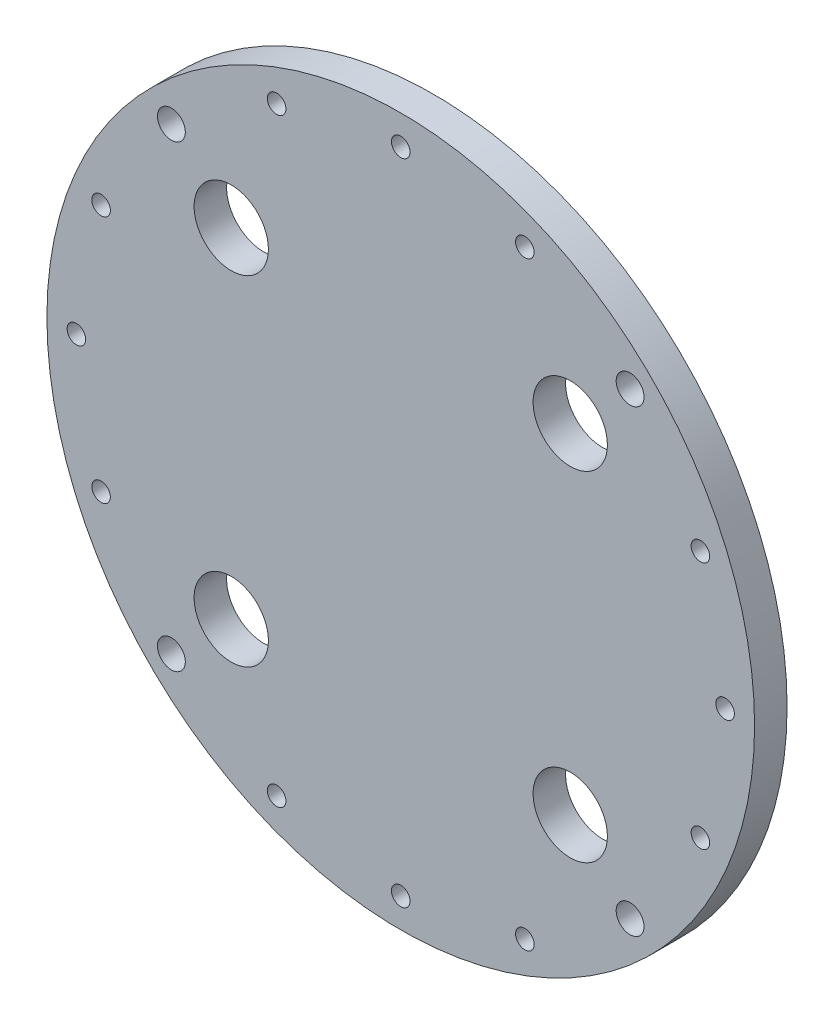
from build123d import *

# Parameters (mm, degrees)
SKETCH1_R           = 76.2
SKETCH1_R_2         = 63.5
BOSS_EXTRUDE1_DEPTH = 28.225
SKETCH3_R           = 3
CUT_EXTRUDE2_DEPTH  = 29.225
SKETCH4_R           = 107.957941083
CUT_EXTRUDE3_DEPTH  = 10.225
SKETCH7_R           = 2
CUT_EXTRUDE4_DEPTH  = 11
SKETCH8_R           = 1
CUT_EXTRUDE5_DEPTH  = 19
SKETCH9_R           = 92.063323974
CUT_EXTRUDE6_DEPTH  = 11
SKETCH10_R          = 2
CUT_EXTRUDE7_DEPTH  = 8
SKETCH11_R          = 63.5
BOSS_EXTRUDE5_DEPTH = 7
SKETCH12_R          = 8
CUT_EXTRUDE8_DEPTH  = 7


with BuildPart() as part:
    # Sketch1 → Boss-Extrude1 (new body)
    with BuildSketch(Plane.XY):
        Circle(SKETCH1_R)
        Circle(SKETCH1_R_2, mode=Mode.SUBTRACT)
    extrude(amount=BOSS_EXTRUDE1_DEPTH)

    # Sketch3 → Cut-Extrude2 (cut, through all)
    with BuildSketch(Plane.XY.offset(28.225)):
        with Locations((-49.391408666, 49.391408666)):
            Circle(SKETCH3_R)
        with Locations((49.391408666, 49.391408666)):
            Circle(SKETCH3_R)
        with Locations((49.391408666, -49.391408666)):
            Circle(SKETCH3_R)
        with Locations((-49.391408666, -49.391408666)):
            Circle(SKETCH3_R)
    extrude(amount=-CUT_EXTRUDE2_DEPTH, mode=Mode.SUBTRACT)

    # Sketch4 → Cut-Extrude3 (cut)
    with BuildSketch(Plane.XY.offset(28.225)):
        Circle(SKETCH4_R)
    extrude(amount=-CUT_EXTRUDE3_DEPTH, mode=Mode.SUBTRACT)

    # Sketch7 → Cut-Extrude4 (cut)
    with BuildSketch(Plane(origin=(0, 0, 0), x_dir=(-1, 0, 0), z_dir=(0, 0, -1))):
        with Locations((0, 69.85)):
            Circle(SKETCH7_R)
        with Locations((69.85, 0)):
            Circle(SKETCH7_R)
        with Locations((0, -69.85)):
            Circle(SKETCH7_R)
        with Locations((-69.85, 0)):
            Circle(SKETCH7_R)
    extrude(amount=-CUT_EXTRUDE4_DEPTH, mode=Mode.SUBTRACT)

    # Sketch8 → Cut-Extrude5 (cut, through all)
    with BuildSketch(Plane(origin=(0, 0, 0), x_dir=(-1, 0, 0), z_dir=(0, 0, -1))):
        with Locations((0, 69.85)):
            Circle(SKETCH8_R)
        with Locations((69.85, 0)):
            Circle(SKETCH8_R)
        with Locations((0, -69.85)):
            Circle(SKETCH8_R)
        with Locations((-69.85, 0)):
            Circle(SKETCH8_R)
    extrude(amount=-CUT_EXTRUDE5_DEPTH, mode=Mode.SUBTRACT)

    # Sketch9 → Cut-Extrude6 (cut)
    with BuildSketch(Plane.XY.offset(18)):
        Circle(SKETCH9_R)
    extrude(amount=-CUT_EXTRUDE6_DEPTH, mode=Mode.SUBTRACT)

    # Sketch10 → Cut-Extrude7 (cut, through all)
    with BuildSketch(Plane.XY.offset(7)):
        with Locations((-64.532985346, 26.730437751)):
            Circle(SKETCH10_R)
        with Locations((-64.532985346, -26.730437751)):
            Circle(SKETCH10_R)
        with Locations((26.730437751, 64.532985346)):
            Circle(SKETCH10_R)
        with Locations((-26.730437751, 64.532985346)):
            Circle(SKETCH10_R)
        with Locations((64.532985346, -26.730437751)):
            Circle(SKETCH10_R)
        with Locations((64.532985346, 26.730437751)):
            Circle(SKETCH10_R)
        with Locations((-26.730437751, -64.532985346)):
            Circle(SKETCH10_R)
        with Locations((26.730437751, -64.532985346)):
            Circle(SKETCH10_R)
    extrude(amount=-CUT_EXTRUDE7_DEPTH, mode=Mode.SUBTRACT)

    # Sketch11 → Boss-Extrude5 (add)
    with BuildSketch(Plane.XY.offset(7)):
        Circle(SKETCH11_R)
    extrude(amount=-BOSS_EXTRUDE5_DEPTH)

    # Sketch12 → Cut-Extrude8 (cut)
    with BuildSketch(Plane.XY.offset(7)):
        with Locations((-36.5, 36.5)):
            Circle(SKETCH12_R)
        with Locations((36.5, 36.5)):
            Circle(SKETCH12_R)
        with Locations((-36.5, -36.5)):
            Circle(SKETCH12_R)
        with Locations((36.5, -36.5)):
            Circle(SKETCH12_R)
    extrude(amount=-CUT_EXTRUDE8_DEPTH, mode=Mode.SUBTRACT)


solid = part.part
